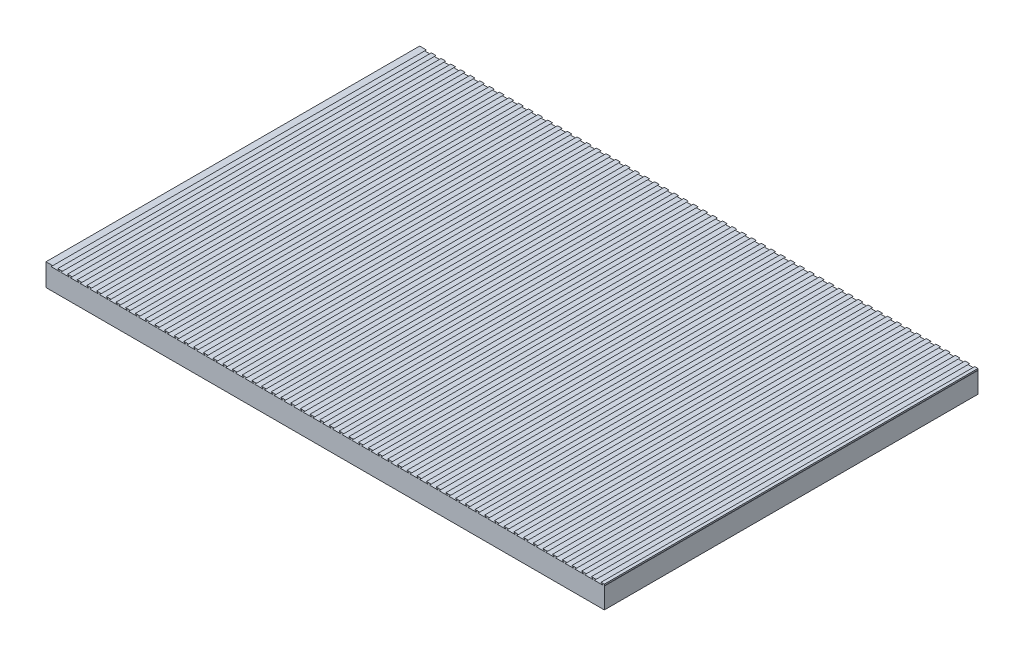
from build123d import *

# Parameters (mm, degrees)
SKETCH1_W           = 760.1
SKETCH1_H           = 508.64
BOSS_EXTRUDE1_DEPTH = 30.48
CUT_EXTRUDE1_DEPTH  = 509.64


with BuildPart() as part:
    # Sketch1 → Boss-Extrude1 (new body)
    with BuildSketch(Plane(origin=(0, 0, 0), x_dir=(1, 0, 0), z_dir=(0, 1, 0))):
        with Locations((380.05, 254.32)):
            Rectangle(SKETCH1_W, SKETCH1_H)
    extrude(amount=BOSS_EXTRUDE1_DEPTH)

    # Sketch2 → Cut-Extrude1 (cut, through all)
    with BuildSketch(Plane.XY):
        Polygon((782.109195477, 30.48), (784.395195477, 28.194), (772.965195477, 28.194), (775.251195477, 30.48), align=None)
        Polygon((762.043195477, 30.48), (768.901195477, 30.48), (771.187195477, 28.194), (759.757195477, 28.194), align=None)
        Polygon((748.835195477, 30.48), (755.693195477, 30.48), (757.979195477, 28.194), (746.549195477, 28.194), align=None)
        Polygon((735.627195477, 30.48), (742.485195477, 30.48), (744.771195477, 28.194), (733.341195477, 28.194), align=None)
        Polygon((722.419195477, 30.48), (729.277195477, 30.48), (731.563195477, 28.194), (720.133195477, 28.194), align=None)
        Polygon((709.211195477, 30.48), (716.069195477, 30.48), (718.355195477, 28.194), (706.925195477, 28.194), align=None)
        Polygon((696.003195477, 30.48), (702.861195477, 30.48), (705.147195477, 28.194), (693.717195477, 28.194), align=None)
        Polygon((682.795195477, 30.48), (689.653195477, 30.48), (691.939195477, 28.194), (680.509195477, 28.194), align=None)
        Polygon((669.587195477, 30.48), (676.445195477, 30.48), (678.731195477, 28.194), (667.301195477, 28.194), align=None)
        Polygon((656.379195477, 30.48), (663.237195477, 30.48), (665.523195477, 28.194), (654.093195477, 28.194), align=None)
        Polygon((643.171195477, 30.48), (650.029195477, 30.48), (652.315195477, 28.194), (640.885195477, 28.194), align=None)
        Polygon((629.963195477, 30.48), (636.821195477, 30.48), (639.107195477, 28.194), (627.677195477, 28.194), align=None)
        Polygon((616.755195477, 30.48), (623.613195477, 30.48), (625.899195477, 28.194), (614.469195477, 28.194), align=None)
        Polygon((603.547195477, 30.48), (610.405195477, 30.48), (612.691195477, 28.194), (601.261195477, 28.194), align=None)
        Polygon((590.339195477, 30.48), (597.197195477, 30.48), (599.483195477, 28.194), (588.053195477, 28.194), align=None)
        Polygon((577.131195477, 30.48), (583.989195477, 30.48), (586.275195477, 28.194), (574.845195477, 28.194), align=None)
        Polygon((563.923195477, 30.48), (570.781195477, 30.48), (573.067195477, 28.194), (561.637195477, 28.194), align=None)
        Polygon((550.715195477, 30.48), (557.573195477, 30.48), (559.859195477, 28.194), (548.429195477, 28.194), align=None)
        Polygon((537.507195477, 30.48), (544.365195477, 30.48), (546.651195477, 28.194), (535.221195477, 28.194), align=None)
        Polygon((524.299195477, 30.48), (531.157195477, 30.48), (533.443195477, 28.194), (522.013195477, 28.194), align=None)
        Polygon((511.091195477, 30.48), (517.949195477, 30.48), (520.235195477, 28.194), (508.805195477, 28.194), align=None)
        Polygon((497.883195477, 30.48), (504.741195477, 30.48), (507.027195477, 28.194), (495.597195477, 28.194), align=None)
        Polygon((484.675195477, 30.48), (491.533195477, 30.48), (493.819195477, 28.194), (482.389195477, 28.194), align=None)
        Polygon((471.467195477, 30.48), (478.325195477, 30.48), (480.611195477, 28.194), (469.181195477, 28.194), align=None)
        Polygon((458.259195477, 30.48), (465.117195477, 30.48), (467.403195477, 28.194), (455.973195477, 28.194), align=None)
        Polygon((445.051195477, 30.48), (451.909195477, 30.48), (454.195195477, 28.194), (442.765195477, 28.194), align=None)
        Polygon((431.843195477, 30.48), (438.701195477, 30.48), (440.987195477, 28.194), (429.557195477, 28.194), align=None)
        Polygon((418.635195477, 30.48), (425.493195477, 30.48), (427.779195477, 28.194), (416.349195477, 28.194), align=None)
        Polygon((405.427195477, 30.48), (412.285195477, 30.48), (414.571195477, 28.194), (403.141195477, 28.194), align=None)
        Polygon((392.219195477, 30.48), (399.077195477, 30.48), (401.363195477, 28.194), (389.933195477, 28.194), align=None)
        Polygon((379.011195477, 30.48), (385.869195477, 30.48), (388.155195477, 28.194), (376.725195477, 28.194), align=None)
        Polygon((365.803195477, 30.48), (372.661195477, 30.48), (374.947195477, 28.194), (363.517195477, 28.194), align=None)
        Polygon((352.595195477, 30.48), (359.453195477, 30.48), (361.739195477, 28.194), (350.309195477, 28.194), align=None)
        Polygon((339.387195477, 30.48), (346.245195477, 30.48), (348.531195477, 28.194), (337.101195477, 28.194), align=None)
        Polygon((326.179195477, 30.48), (333.037195477, 30.48), (335.323195477, 28.194), (323.893195477, 28.194), align=None)
        Polygon((312.971195477, 30.48), (319.829195477, 30.48), (322.115195477, 28.194), (310.685195477, 28.194), align=None)
        Polygon((299.763195477, 30.48), (306.621195477, 30.48), (308.907195477, 28.194), (297.477195477, 28.194), align=None)
        Polygon((286.555195477, 30.48), (293.413195477, 30.48), (295.699195477, 28.194), (284.269195477, 28.194), align=None)
        Polygon((273.347195477, 30.48), (280.205195477, 30.48), (282.491195477, 28.194), (271.061195477, 28.194), align=None)
        Polygon((260.139195477, 30.48), (266.997195477, 30.48), (269.283195477, 28.194), (257.853195477, 28.194), align=None)
        Polygon((246.931195477, 30.48), (253.789195477, 30.48), (256.075195477, 28.194), (244.645195477, 28.194), align=None)
        Polygon((233.723195477, 30.48), (240.581195477, 30.48), (242.867195477, 28.194), (231.437195477, 28.194), align=None)
        Polygon((220.515195477, 30.48), (227.373195477, 30.48), (229.659195477, 28.194), (218.229195477, 28.194), align=None)
        Polygon((207.307195477, 30.48), (214.165195477, 30.48), (216.451195477, 28.194), (205.021195477, 28.194), align=None)
        Polygon((194.099195477, 30.48), (200.957195477, 30.48), (203.243195477, 28.194), (191.813195477, 28.194), align=None)
        Polygon((180.891195477, 30.48), (187.749195477, 30.48), (190.035195477, 28.194), (178.605195477, 28.194), align=None)
        Polygon((167.683195477, 30.48), (174.541195477, 30.48), (176.827195477, 28.194), (165.397195477, 28.194), align=None)
        Polygon((154.475195477, 30.48), (161.333195477, 30.48), (163.619195477, 28.194), (152.189195477, 28.194), align=None)
        Polygon((141.267195477, 30.48), (148.125195477, 30.48), (150.411195477, 28.194), (138.981195477, 28.194), align=None)
        Polygon((128.059195477, 30.48), (134.917195477, 30.48), (137.203195477, 28.194), (125.773195477, 28.194), align=None)
        Polygon((114.851195477, 30.48), (121.709195477, 30.48), (123.995195477, 28.194), (112.565195477, 28.194), align=None)
        Polygon((101.643195477, 30.48), (108.501195477, 30.48), (110.787195477, 28.194), (99.357195477, 28.194), align=None)
        Polygon((88.435195477, 30.48), (95.293195477, 30.48), (97.579195477, 28.194), (86.149195477, 28.194), align=None)
        Polygon((75.227195477, 30.48), (82.085195477, 30.48), (84.371195477, 28.194), (72.941195477, 28.194), align=None)
        Polygon((62.019195477, 30.48), (68.877195477, 30.48), (71.163195477, 28.194), (59.733195477, 28.194), align=None)
        Polygon((48.811195477, 30.48), (55.669195477, 30.48), (57.955195477, 28.194), (46.525195477, 28.194), align=None)
        Polygon((35.603195477, 30.48), (42.461195477, 30.48), (44.747195477, 28.194), (33.317195477, 28.194), align=None)
        Polygon((22.395195477, 30.48), (29.253195477, 30.48), (31.539195477, 28.194), (20.109195477, 28.194), align=None)
        Polygon((9.187195477, 30.48), (16.045195477, 30.48), (18.331195477, 28.194), (6.901195477, 28.194), align=None)
    extrude(amount=-CUT_EXTRUDE1_DEPTH, mode=Mode.SUBTRACT)


solid = part.part
